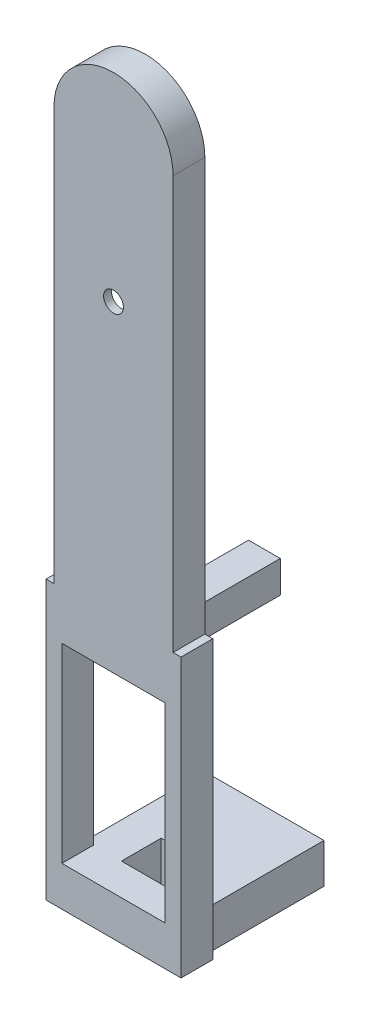
from build123d import *

# Parameters (mm, degrees)
EXTRUDE_1_DEPTH     = 4
CUT_EXTRUDE_1_DEPTH = 3
SKETCH_5_R          = 1.25
CUT_EXTRUDE_2_DEPTH = 12.4
SKETCH_6_W          = 17
SKETCH_6_H          = 35
EXTRUDE_2_DEPTH     = 4
SKETCH_7_W          = 13
SKETCH_7_H          = 24
CUT_EXTRUDE_3_DEPTH = 12.1
SKETCH_8_W          = 4
SKETCH_8_H          = 4
SKETCH_8_R          = 1.25
EXTRUDE_3_DEPTH     = 15
EXTRUDE_4_DEPTH     = 5
SKETCH_10_R         = 1.25
CUT_EXTRUDE_4_DEPTH = 35


with BuildPart() as part:
    # 草圖1 → 填料-伸長1 (new body)
    with BuildSketch(Plane.XY):
        with BuildLine():
            Line((7.5, 0), (7.5, 52))
            ThreePointArc((7.5, 52), (0, 59.5), (-7.5, 52))
            Line((-7.5, 52), (-7.5, 0))
            Line((-7.5, 0), (7.5, 0))
        make_face()
    extrude(amount=EXTRUDE_1_DEPTH)

    # 草圖3 → 除料-伸長1 (cut)
    with BuildSketch(Plane.XY):
        with BuildLine():
            ThreePointArc((-2.132795501, 52), (0, 54.132795501), (2.132795501, 52))
            Line((2.132795501, 52), (5, 34.5))
            Line((5, 34.5), (2.114741289, 16.658021353))
            ThreePointArc((2.114741289, 16.658021353), (-0.171540182, 14.864665347), (-2.142213835, 17))
            Line((-2.142213835, 17), (-5, 34.5))
            Line((-5, 34.5), (-2.132795501, 52))
        make_face()
    extrude(amount=CUT_EXTRUDE_1_DEPTH, mode=Mode.SUBTRACT)

    # 草圖5 → 除料-伸長2 (cut)
    with BuildSketch(Plane.XY):
        with Locations((0, 34.5)):
            Circle(SKETCH_5_R)
    extrude(amount=CUT_EXTRUDE_2_DEPTH, mode=Mode.SUBTRACT)

    # 草圖6 → 填料-伸長2 (add)
    with BuildSketch(Plane.XY):
        with Locations((0, -17.5)):
            Rectangle(SKETCH_6_W, SKETCH_6_H)
    extrude(amount=EXTRUDE_2_DEPTH)

    # 草圖7 → 除料-伸長3 (cut)
    with BuildSketch(Plane.XY):
        with Locations((0, -18)):
            Rectangle(SKETCH_7_W, SKETCH_7_H)
    extrude(amount=CUT_EXTRUDE_3_DEPTH, mode=Mode.SUBTRACT)

    # 草圖8 → 填料-伸長3 (add)
    with BuildSketch(Plane.XY):
        with Locations((0, -4)):
            Rectangle(SKETCH_8_W, SKETCH_8_H)
        with Locations((0, -4)):
            Circle(SKETCH_8_R, mode=Mode.SUBTRACT)
    extrude(amount=-EXTRUDE_3_DEPTH)

    # 草圖9 → 填料-伸長4 (add)
    with BuildSketch(Plane(origin=(0, -35, 0), x_dir=(1, 0, 0), z_dir=(0, 1, 0))):
        Polygon((-7.5, 0), (-3, 0), (-3, 5), (3, 5), (3, 0), (7.5, 0), (7.5, 15), (-7.5, 15), align=None)
    extrude(amount=EXTRUDE_4_DEPTH)

    # 草圖10 → 除料-伸長4 (cut)
    with BuildSketch(Plane.XY):
        with Locations((0, -32.5)):
            Circle(SKETCH_10_R)
    extrude(amount=-CUT_EXTRUDE_4_DEPTH, mode=Mode.SUBTRACT)


solid = part.part
